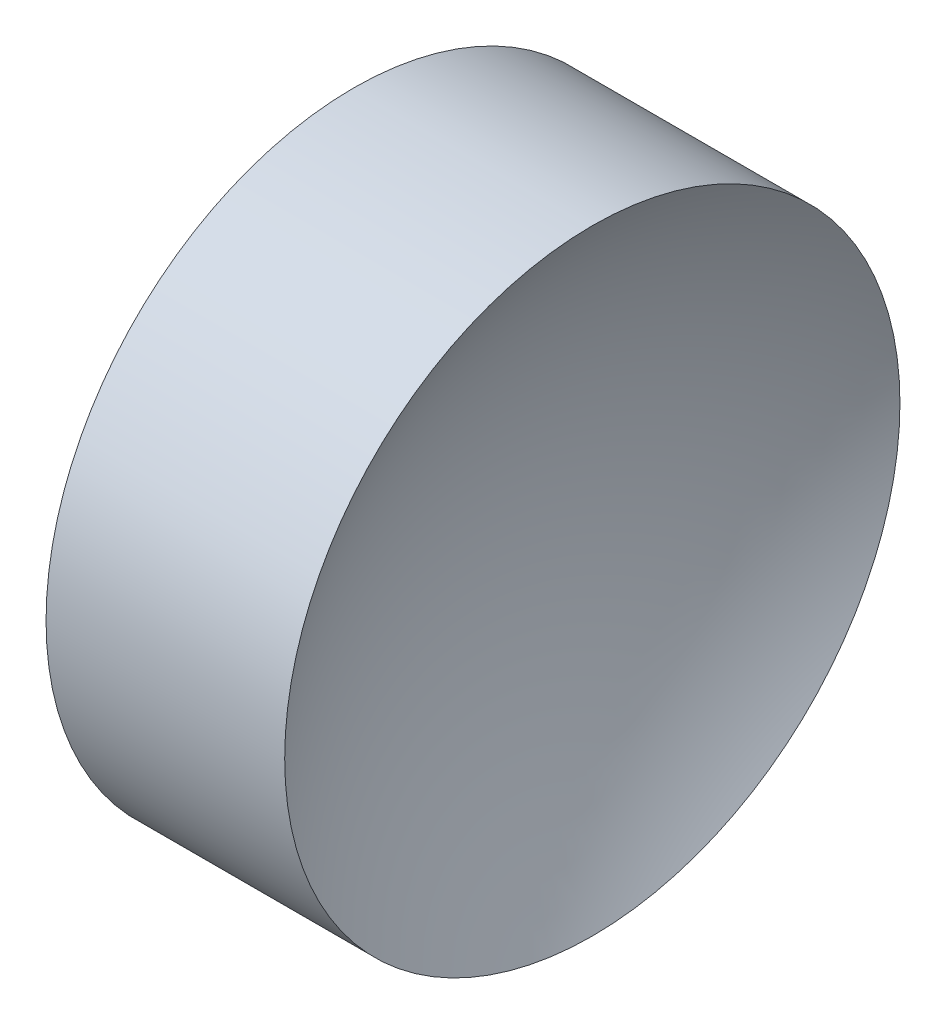
from build123d import *


with BuildPart() as part:
    # 草图1 → 旋转1 (revolve)
    with BuildSketch(Plane.XY, mode=Mode.PRIVATE) as revolve_1_sk:
        with BuildLine():
            Line((22.200875489, 13.031126091), (22.200875489, 16.181126091))
            Line((22.200875489, 16.181126091), (24.644394527, 16.181126091))
            ThreePointArc((24.644394527, 16.181126091), (23.941821112, 14.675261744), (23.700875489, 13.031126091))
            Line((23.700875489, 13.031126091), (22.200875489, 13.031126091))
        make_face()
    revolve(revolve_1_sk.sketch.rotate(Axis((21.156471922, 13.031126091, 0), (1, 0, 0)), 180), axis=Axis((21.156471922, 13.031126091, 0), (1, 0, 0)))  # turned: the seam where the file's is


solid = part.part
